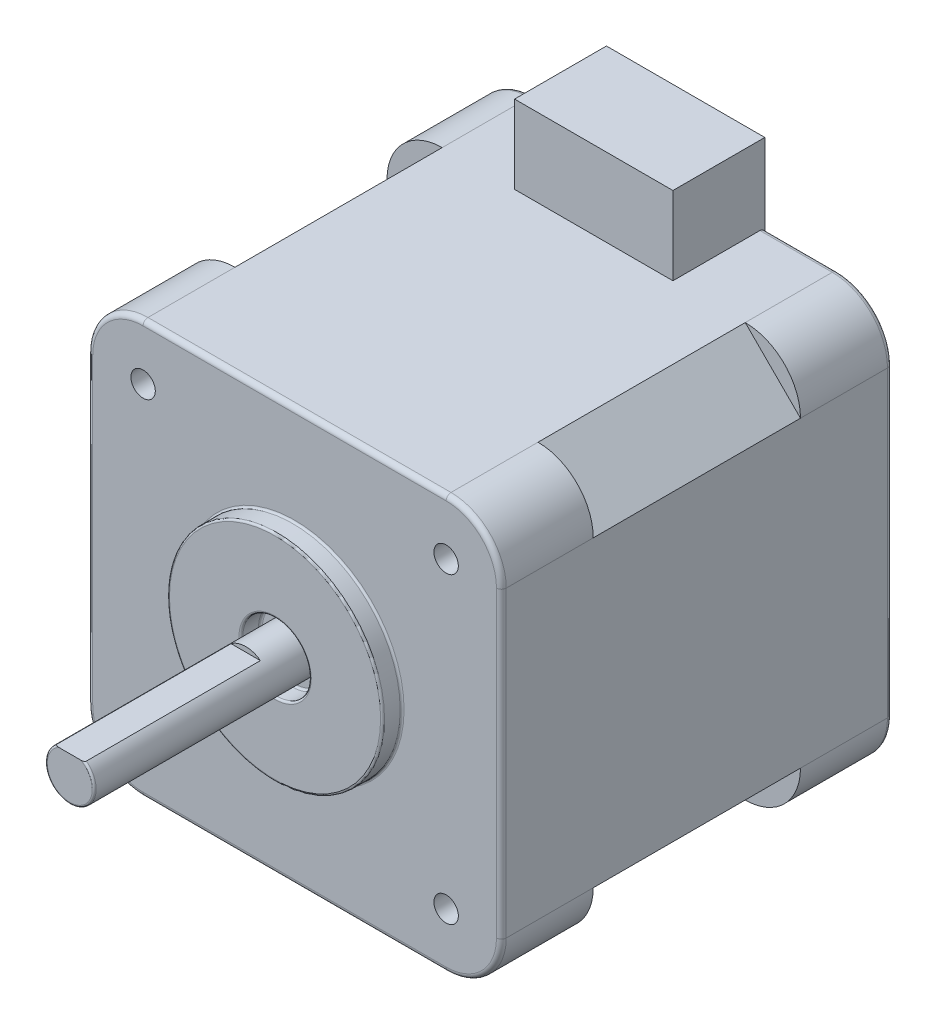
from build123d import *

# Parameters (mm, degrees)
SKETCH_1_W               = 42.3
SKETCH_1_H               = 42.3
EXTRUDE_1_DEPTH          = 10.6
CHAMFER_1_SIZE           = 5.65
SKETCH_3_W               = 42.3
SKETCH_3_H               = 42.3
EXTRUDE_2_DEPTH          = 9.4
FILLET_1_R               = 5.65
HOLE_WIZARD_M3_1_D       = 2.5
HOLE_WIZARD_M3_1_DEPTH   = 4.5
HOLE_WIZARD_M3_1_TIP     = 0.751075774
SKETCH_6_W               = 42.3
SKETCH_6_H               = 42.3
EXTRUDE_3_DEPTH          = 9.4
FILLET_2_R               = 5.65
SKETCH_7_W               = 16.2
SKETCH_7_H               = 9.4
EXTRUDE_4_DEPTH          = 8
SKETCH_8_R               = 11
EXTRUDE_5_DEPTH          = 2
FILLET_3_R               = 0.2
CUT_EXTRUDE_2_REACH      = 4
SKETCH_9_R               = 3.5
FILLET_4_R               = 0.2
SKETCH_11_R              = 2.5
EXTRUDE_7_DEPTH          = 23
FILLET_5_R               = 0.2
SKETCH_12_W              = 18
SKETCH_12_H              = 0.5
CUT_EXTRUDE_3_DEPTH      = 22.1500001
CUT_EXTRUDE_3_DEPTH_BACK = 22.1500001
FILLET_6_R               = 0.5


with BuildPart() as part:
    # 草图1 → 凸台-拉伸1 (new body, symmetric)
    with BuildSketch(Plane.XY):
        Rectangle(SKETCH_1_W, SKETCH_1_H)
    extrude(amount=EXTRUDE_1_DEPTH, both=True)

    # 倒角1
    chamfer_1_edges = [part.edges().sort_by_distance(p)[0] for p in [
        (21.15, -21.15, 0),
        (-21.15, -21.15, 0),
        (-21.15, 21.15, 0),
        (21.15, 21.15, 0),
    ]]
    chamfer(chamfer_1_edges, length=CHAMFER_1_SIZE)

    # 草图3 → 凸台-拉伸2 (add)
    with BuildSketch(Plane.XY.offset(10.6)):
        Rectangle(SKETCH_3_W, SKETCH_3_H)
    extrude(amount=EXTRUDE_2_DEPTH)

    # 圆角1
    fillet_1_edges = [part.edges().sort_by_distance(p)[0] for p in [
        (21.15, 21.15, 15.3),
        (21.15, -21.15, 15.3),
        (-21.15, -21.15, 15.3),
        (-21.15, 21.15, 15.3),
    ]]
    fillet(fillet_1_edges, radius=FILLET_1_R)

    # M3 螺纹孔1
    with Locations(Plane.XY.offset(20)):
        with Locations((-15.5, -15.5), (15.5, -15.5), (15.5, 15.5), (-15.5, 15.5)):
            Hole(HOLE_WIZARD_M3_1_D / 2, depth=HOLE_WIZARD_M3_1_DEPTH)
            with Locations((0, 0, -(HOLE_WIZARD_M3_1_DEPTH + HOLE_WIZARD_M3_1_TIP / 2))):  # 118° drill point
                Cone(0, HOLE_WIZARD_M3_1_D / 2, HOLE_WIZARD_M3_1_TIP, mode=Mode.SUBTRACT)

    # 草图6 → 凸台-拉伸3 (add)
    with BuildSketch(Plane(origin=(0, 0, -10.6), x_dir=(-1, 0, 0), z_dir=(0, 0, -1))):
        Rectangle(SKETCH_6_W, SKETCH_6_H)
    extrude(amount=EXTRUDE_3_DEPTH)

    # 圆角2
    fillet_2_edges = [part.edges().sort_by_distance(p)[0] for p in [
        (-21.15, -21.15, -15.3),
        (21.15, -21.15, -15.3),
        (21.15, 21.15, -15.3),
        (-21.15, 21.15, -15.3),
    ]]
    fillet(fillet_2_edges, radius=FILLET_2_R)

    # 草图7 → 凸台-拉伸4 (add)
    with BuildSketch(Plane(origin=(0, 21.15, 0), x_dir=(1, 0, 0), z_dir=(0, 1, 0))):
        with Locations((0, 15.3)):
            Rectangle(SKETCH_7_W, SKETCH_7_H)
    extrude(amount=EXTRUDE_4_DEPTH)

    # 草图8 → 凸台-拉伸5 (add)
    with BuildSketch(Plane.XY.offset(20)):
        Circle(SKETCH_8_R)
    extrude(amount=EXTRUDE_5_DEPTH)

    # 圆角3
    fillet_3_edges = [part.edges().sort_by_distance(p)[0] for p in [
        (-11, 0, 20),
        (-11, 0, 22),
    ]]
    fillet(fillet_3_edges, radius=FILLET_3_R)

    # 草图9 → 切除-拉伸2 (cut, up to next)
    with BuildSketch(Plane.XY.offset(20), mode=Mode.PRIVATE) as cut_extrude_2_sk1:
        Circle(SKETCH_9_R)
    cut_extrude_2_tool1 = extrude(cut_extrude_2_sk1.sketch, amount=CUT_EXTRUDE_2_REACH, mode=Mode.PRIVATE) & part.part
    add(cut_extrude_2_tool1.solids().sort_by_distance((0, 0, 20))[0], mode=Mode.SUBTRACT)

    # 圆角4
    fillet_4_edges = [part.edges().sort_by_distance(p)[0] for p in [
        (-3.5, 0, 20),
        (-3.5, 0, 22),
    ]]
    fillet(fillet_4_edges, radius=FILLET_4_R)

    # 草图11 → 凸台-拉伸7 (add)
    with BuildSketch(Plane.XY.offset(20)):
        Circle(SKETCH_11_R)
    extrude(amount=EXTRUDE_7_DEPTH)

    # 圆角5
    fillet_5_edges = [part.edges().sort_by_distance(p)[0] for p in [
        (-2.5, 0, 43),
    ]]
    fillet(fillet_5_edges, radius=FILLET_5_R)

    # 草图12 → 切除-拉伸3 (cut, two sides)
    with BuildSketch(Plane(origin=(0, 0, 0), x_dir=(0, 0, -1), z_dir=(1, 0, 0))) as cut_extrude_3_sk:
        with Locations((-34, 2.25)):
            Rectangle(SKETCH_12_W, SKETCH_12_H)
    extrude(amount=CUT_EXTRUDE_3_DEPTH, mode=Mode.SUBTRACT)
    extrude(cut_extrude_3_sk.sketch, amount=-CUT_EXTRUDE_3_DEPTH_BACK, mode=Mode.SUBTRACT)

    # 圆角6
    fillet_6_edges = [part.edges().sort_by_distance(p)[0] for p in [
        (-21.15, 0, -20),
        (0, -21.15, -20),
        (21.15, 0, -20),
        (-11.8, 21.15, -20),
        (-19.495153314, 19.495153314, -20),
        (19.495153314, 19.495153314, -20),
        (19.495153314, -19.495153314, -20),
        (-19.495153314, -19.495153314, -20),
        (11.8, 21.15, -20),
        (0, 21.15, 20),
        (21.15, 0, 20),
        (-21.15, 0, 20),
        (0, -21.15, 20),
        (-19.495153314, 19.495153314, 20),
        (-19.495153314, -19.495153314, 20),
        (19.495153314, -19.495153314, 20),
        (19.495153314, 19.495153314, 20),
    ]]
    fillet(fillet_6_edges, radius=FILLET_6_R)


solid = part.part
